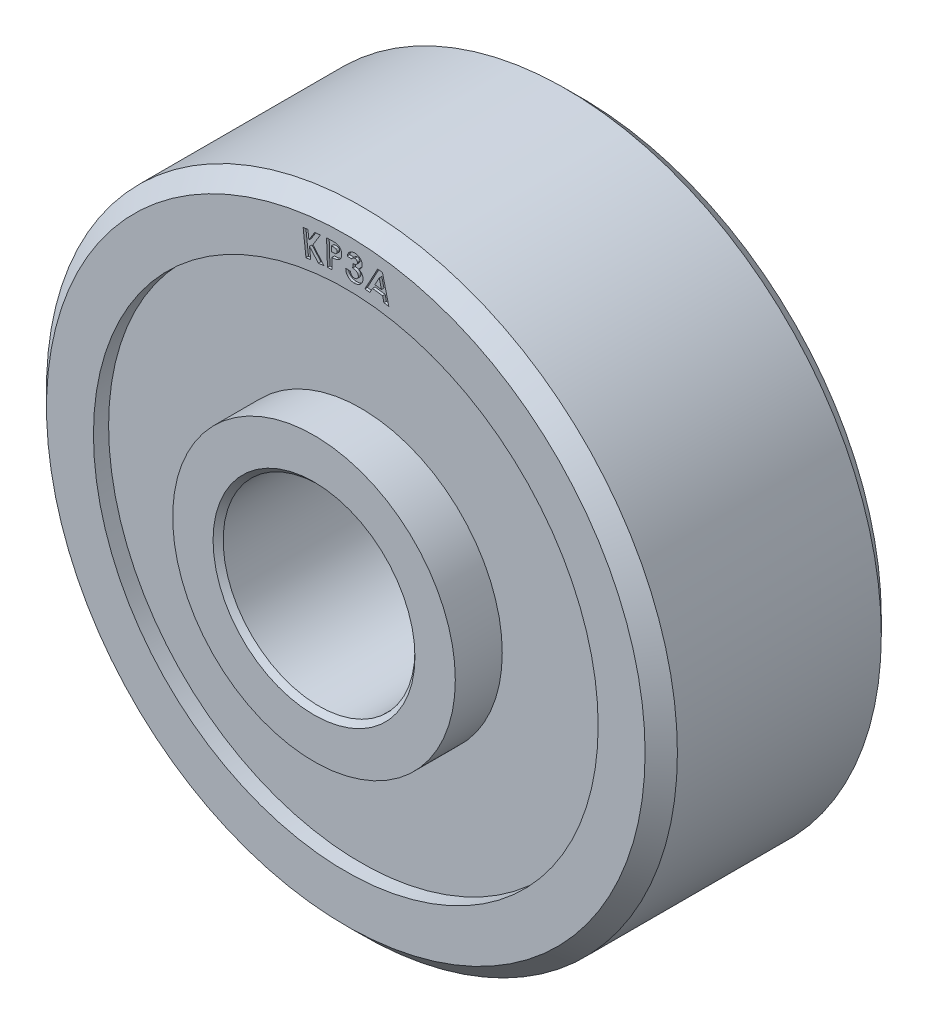
from build123d import *

# Parameters (mm, degrees)
CUT_EXTRUDE1_DEPTH = 0.0635


with BuildPart() as part:
    # Sketch1 → Revolve1 (revolve)
    with BuildSketch(Plane(origin=(0, 0, 0), x_dir=(0, 0, -1), z_dir=(1, 0, 0))):
        Polygon((-3.7719, 2.54), (-3.7719, 3.556), (-2.5908, 3.556), (-2.5908, 6.35), (-2.9718, 6.35), (-2.9718, 7.5311), (-2.5654, 7.9375), (2.5654, 7.9375), (2.9718, 7.5311), (2.9718, 6.35), (2.5908, 6.35), (2.5908, 3.556), (3.7719, 3.556), (3.7719, 2.54), (3.6449, 2.413), (-3.6449, 2.413), align=None)
    revolve(axis=Axis((0, 0, 0), (0, 0, -1)))

    # Sketch2 → Cut-Extrude1 (cut)
    with BuildSketch(Plane.XY.offset(2.9718)):
        Polygon((-1.073681475, 7.149950284), (-0.953219737, 7.163688265), (-0.92879666, 6.9484599), (-0.783530233, 7.182895997), (-0.64017186, 7.199305252), (-0.827033839, 6.895288826), (-0.547694897, 6.576007977), (-0.68889081, 6.559853129), (-0.91365944, 6.815659419), (-0.881985762, 6.537974122), (-1.002447501, 6.524236142), align=None)
        with BuildLine():
            Line((-0.483895388, 7.216524684), (-0.356437455, 7.220976808))
            add(Edge.make_bspline(
                [(-0.356437455, 7.220976808), (-0.348127565, 7.221174763), (-0.332060567, 7.221557506), (-0.30885576, 7.22165103), (-0.287434102, 7.220847317), (-0.267813394, 7.219564911), (-0.249965241, 7.217315038), (-0.233827559, 7.214807961), (-0.219502285, 7.211370346), (-0.20679939, 7.207241827), (-0.195285698, 7.202452443), (-0.184489444, 7.196976494), (-0.174371586, 7.190545045), (-0.164643507, 7.18364255), (-0.155709146, 7.175752396), (-0.147242277, 7.167209654), (-0.139416779, 7.157815249), (-0.13216206, 7.147734921), (-0.125493288, 7.137087541), (-0.119818082, 7.125715329), (-0.114848545, 7.113859232), (-0.110591185, 7.101472639), (-0.107345972, 7.088476793), (-0.104800117, 7.074928752), (-0.102964288, 7.060829844), (-0.102513509, 7.051207939), (-0.102284811, 7.046326367)],
                knots=[0, 0, 0, 0, 2.4937e-05, 4.8215e-05, 6.9599e-05, 8.9238e-05, 0.000107178, 0.000123552, 0.000138207, 0.000151321, 0.000163581, 0.000175585, 0.000187585, 0.000199519, 0.000211329, 0.000223292, 0.000235573, 0.000247964, 0.000260531, 0.000273217, 0.000286045, 0.000299078, 0.000312468, 0.00032619, 0.000340421, 0.000355077, 0.000355077, 0.000355077, 0.000355077], degree=3))
            add(Edge.make_bspline(
                [(-0.102284811, 7.046326367), (-0.10221945, 7.040941319), (-0.102090653, 7.03032981), (-0.10302249, 7.014700607), (-0.105433602, 6.999812313), (-0.108499428, 6.985502152), (-0.113041424, 6.971928231), (-0.118443712, 6.958891094), (-0.125131278, 6.946598266), (-0.132893446, 6.935057889), (-0.141572795, 6.924247517), (-0.151009096, 6.914116137), (-0.16130768, 6.904893953), (-0.172351664, 6.896344793), (-0.184309667, 6.888833082), (-0.196946646, 6.881851982), (-0.210471163, 6.875896783), (-0.219882564, 6.872589605), (-0.224654602, 6.870912705)],
                knots=[0, 0, 0, 0, 1.6155e-05, 3.1834e-05, 4.6892e-05, 6.1365e-05, 7.5686e-05, 8.9766e-05, 0.000103654, 0.00011759, 0.000131436, 0.000145205, 0.000159076, 0.000172865, 0.000187051, 0.000201395, 0.000216145, 0.000231316, 0.000231316, 0.000231316, 0.000231316], degree=3))
            add(Edge.make_bspline(
                [(-0.224654602, 6.870912705), (-0.227823905, 6.86997978), (-0.234696434, 6.867956764), (-0.246063162, 6.865653412), (-0.259162985, 6.863444281), (-0.274089942, 6.861835848), (-0.290728728, 6.859914592), (-0.309235014, 6.858620439), (-0.329503833, 6.857458742), (-0.343631033, 6.856936912), (-0.350967703, 6.85666591)],
                knots=[0, 0, 0, 0, 9.907e-06, 2.1483e-05, 3.4763e-05, 4.9752e-05, 6.651e-05, 8.5008e-05, 0.000105392, 0.000127417, 0.000127417, 0.000127417, 0.000127417], degree=3))
            Line((-0.350967703, 6.85666591), (-0.341554642, 6.589156896))
            Line((-0.341554642, 6.589156896), (-0.461761974, 6.58495918))
            Line((-0.461761974, 6.58495918), (-0.483895388, 7.216524684))
        make_face()
        with BuildLine():
            Line((-0.355038216, 6.973820357), (-0.316877158, 6.975092393))
            add(Edge.make_bspline(
                [(-0.316877158, 6.975092393), (-0.309959449, 6.9753884), (-0.297201618, 6.975934305), (-0.279843375, 6.977875287), (-0.265834277, 6.98007101), (-0.254829165, 6.983249091), (-0.246184433, 6.987579906), (-0.238737157, 6.992537719), (-0.232503589, 6.998742932), (-0.227207837, 7.005840535), (-0.222955991, 7.013830404), (-0.220269028, 7.022737354), (-0.218462128, 7.032260401), (-0.21851933, 7.038854735), (-0.218548833, 7.042255854)],
                knots=[0, 0, 0, 0, 2.0766e-05, 3.8297e-05, 5.2371e-05, 6.3276e-05, 7.2492e-05, 8.1277e-05, 9.0002e-05, 9.8728e-05, 0.000107775, 0.000116987, 0.000126545, 0.000136724, 0.000136724, 0.000136724, 0.000136724], degree=3))
            add(Edge.make_bspline(
                [(-0.218548833, 7.042255854), (-0.21873044, 7.04519037), (-0.219083288, 7.0508919), (-0.220802862, 7.0590735), (-0.223188289, 7.066655055), (-0.226455496, 7.073634686), (-0.230939657, 7.079752879), (-0.235972442, 7.085392653), (-0.241985674, 7.090354688), (-0.246493613, 7.09302784), (-0.248823272, 7.0944093)],
                knots=[0, 0, 0, 0, 8.81e-06, 1.7117e-05, 2.5002e-05, 3.2626e-05, 4.0108e-05, 4.7672e-05, 5.5262e-05, 6.3379e-05, 6.3379e-05, 6.3379e-05, 6.3379e-05], degree=3))
            add(Edge.make_bspline(
                [(-0.248823272, 7.0944093), (-0.250751771, 7.095392779), (-0.254833076, 7.097474129), (-0.261826658, 7.099712609), (-0.269859854, 7.101380369), (-0.278923208, 7.102982514), (-0.289127959, 7.103943951), (-0.300420239, 7.104397059), (-0.312765678, 7.104534188), (-0.321329592, 7.104316916), (-0.325781405, 7.104203971)],
                knots=[0, 0, 0, 0, 6.486e-06, 1.3727e-05, 2.1936e-05, 3.1096e-05, 4.1323e-05, 5.2655e-05, 6.4995e-05, 7.8353e-05, 7.8353e-05, 7.8353e-05, 7.8353e-05], degree=3))
            Line((-0.325781405, 7.104203971), (-0.359617543, 7.10305914))
            Line((-0.359617543, 7.10305914), (-0.355038216, 6.973820357))
        make_face(mode=Mode.SUBTRACT)
        with BuildLine():
            Line((0.150369045, 7.072643459), (0.034868244, 7.077477193))
            add(Edge.make_bspline(
                [(0.034868244, 7.077477193), (0.035930136, 7.083134845), (0.038015251, 7.09424412), (0.042505288, 7.11031614), (0.047995965, 7.125473202), (0.05432215, 7.13980968), (0.061752106, 7.15317407), (0.069986869, 7.165714019), (0.079351921, 7.177277613), (0.086322676, 7.184259549), (0.089820167, 7.18776265)],
                knots=[0, 0, 0, 0, 1.7263e-05, 3.3898e-05, 4.9993e-05, 6.5595e-05, 8.0853e-05, 9.5812e-05, 0.000110553, 0.000125397, 0.000125397, 0.000125397, 0.000125397], degree=3))
            add(Edge.make_bspline(
                [(0.089820167, 7.18776265), (0.094865971, 7.192274987), (0.104860211, 7.201212588), (0.121206297, 7.21270804), (0.138507318, 7.222111377), (0.156533654, 7.229846028), (0.175477636, 7.235592405), (0.195265974, 7.23931578), (0.215872831, 7.241521421), (0.229866253, 7.241216339), (0.236994646, 7.241060927)],
                knots=[0, 0, 0, 0, 2.0296e-05, 4.02e-05, 5.9783e-05, 7.9275e-05, 9.8952e-05, 0.000119034, 0.000139615, 0.000160985, 0.000160985, 0.000160985, 0.000160985], degree=3))
            add(Edge.make_bspline(
                [(0.236994646, 7.241060927), (0.243326567, 7.240680157), (0.255807691, 7.239929605), (0.274004431, 7.236615571), (0.29143556, 7.232077493), (0.30799456, 7.225998017), (0.323653648, 7.218273359), (0.338414905, 7.209087101), (0.352444165, 7.198458605), (0.365305592, 7.186320664), (0.377179935, 7.173386384), (0.387158219, 7.159525384), (0.395899686, 7.145400959), (0.402531779, 7.130538271), (0.407908864, 7.115349451), (0.411286837, 7.099534653), (0.413145645, 7.083247045), (0.412993733, 7.072223968), (0.412917122, 7.066664894)],
                knots=[0, 0, 0, 0, 1.9015e-05, 3.7481e-05, 5.5376e-05, 7.3004e-05, 9.0298e-05, 0.000107665, 0.000125092, 0.000143003, 0.000160655, 0.000177676, 0.000194168, 0.000210391, 0.000226402, 0.00024242, 0.000258799, 0.000275464, 0.000275464, 0.000275464, 0.000275464], degree=3))
            add(Edge.make_bspline(
                [(0.412917122, 7.066664894), (0.41235476, 7.05980872), (0.411240079, 7.046218812), (0.406043562, 7.026458501), (0.39789868, 7.007804099), (0.387022208, 6.990325064), (0.373534633, 6.974196295), (0.357216573, 6.960069836), (0.33865037, 6.947342211), (0.324785783, 6.940798127), (0.317641682, 6.937426111)],
                knots=[0, 0, 0, 0, 2.0607e-05, 4.0847e-05, 6.0957e-05, 8.1466e-05, 0.000102411, 0.00012377, 0.000146033, 0.000169698, 0.000169698, 0.000169698, 0.000169698], degree=3))
            add(Edge.make_bspline(
                [(0.317641682, 6.937426111), (0.32224211, 6.935698678), (0.331301172, 6.932297053), (0.344369065, 6.926332147), (0.35651554, 6.919430047), (0.367977299, 6.911964248), (0.378419285, 6.903438687), (0.388195142, 6.894343798), (0.397222968, 6.884499408), (0.405133722, 6.873803404), (0.412319627, 6.86262639), (0.418401705, 6.850899497), (0.423549689, 6.838747006), (0.427584264, 6.826137821), (0.430707776, 6.813135676), (0.432507079, 6.799669109), (0.433659619, 6.785817667), (0.433400721, 6.776430836), (0.433269686, 6.771679918)],
                knots=[0, 0, 0, 0, 1.474e-05, 2.9026e-05, 4.3037e-05, 5.662e-05, 7.001e-05, 8.3419e-05, 9.6656e-05, 0.000110013, 0.000123281, 0.000136481, 0.000149592, 0.000162827, 0.000176156, 0.000189648, 0.000203551, 0.000217798, 0.000217798, 0.000217798, 0.000217798], degree=3))
            add(Edge.make_bspline(
                [(0.433269686, 6.771679918), (0.432765993, 6.764711087), (0.431776994, 6.751027827), (0.428037351, 6.730975818), (0.422331069, 6.711865528), (0.414582575, 6.693650574), (0.40509285, 6.676242582), (0.393306005, 6.65995426), (0.379980386, 6.644293353), (0.364610651, 6.629962516), (0.347911834, 6.616892312), (0.330107991, 6.605507084), (0.311186133, 6.596161421), (0.291335816, 6.588659086), (0.270460274, 6.583017939), (0.24860161, 6.579425993), (0.225753103, 6.577364888), (0.21020071, 6.577751668), (0.202268084, 6.577948948)],
                knots=[0, 0, 0, 0, 2.0948e-05, 4.1132e-05, 6.1053e-05, 8.0662e-05, 0.000100418, 0.000120395, 0.00014087, 0.000162017, 0.000183315, 0.000204417, 0.000225295, 0.00024651, 0.000267987, 0.000290049, 0.000312898, 0.000336686, 0.000336686, 0.000336686, 0.000336686], degree=3))
            add(Edge.make_bspline(
                [(0.202268084, 6.577948948), (0.194789086, 6.57839721), (0.180137141, 6.579275391), (0.158818194, 6.583036753), (0.138491754, 6.587897585), (0.119470159, 6.595108583), (0.101407507, 6.603495029), (0.08465858, 6.613975504), (0.06894446, 6.625940153), (0.054434463, 6.639564585), (0.041370011, 6.654639685), (0.029947511, 6.671061742), (0.02032282, 6.688665923), (0.012188263, 6.707362205), (0.005999826, 6.72734238), (0.001476395, 6.748460036), (-0.001528162, 6.770750316), (-0.002106289, 6.786001906), (-0.002402389, 6.793813331)],
                knots=[0, 0, 0, 0, 2.2459e-05, 4.3998e-05, 6.4854e-05, 8.5057e-05, 0.000104915, 0.000124506, 0.000144198, 0.000164086, 0.000184106, 0.000203937, 0.000223978, 0.000244205, 0.000265004, 0.000286611, 0.000308937, 0.000332377, 0.000332377, 0.000332377, 0.000332377], degree=3))
            Line((-0.002402389, 6.793813331), (0.116532908, 6.788852394))
            add(Edge.make_bspline(
                [(0.116532908, 6.788852394), (0.117083814, 6.784859736), (0.118155397, 6.777093502), (0.120420684, 6.765904569), (0.123316627, 6.755452946), (0.127086473, 6.745877702), (0.13105794, 6.736830411), (0.135943691, 6.728677636), (0.141423976, 6.72128491), (0.149386698, 6.712448448), (0.160822004, 6.703104322), (0.176726451, 6.695042794), (0.194393457, 6.689662842), (0.206893004, 6.688636262), (0.213334791, 6.688107201)],
                knots=[0, 0, 0, 0, 1.2089e-05, 2.3515e-05, 3.4226e-05, 4.4573e-05, 5.4363e-05, 6.3831e-05, 7.3016e-05, 8.1932e-05, 9.9474e-05, 0.00011694, 0.00013513, 0.000154474, 0.000154474, 0.000154474, 0.000154474], degree=3))
            add(Edge.make_bspline(
                [(0.213334791, 6.688107201), (0.216771217, 6.688039897), (0.223530094, 6.687907521), (0.233443515, 6.688862166), (0.242989812, 6.690490656), (0.25212156, 6.693016148), (0.260831182, 6.696454074), (0.269065034, 6.700872918), (0.276904644, 6.706059487), (0.284325582, 6.712017711), (0.29091538, 6.718751106), (0.297039218, 6.725727582), (0.302114685, 6.7333353), (0.306465929, 6.741262829), (0.309780733, 6.749704966), (0.312345821, 6.758466048), (0.313995689, 6.767683154), (0.314473578, 6.773963686), (0.314716001, 6.777149669)],
                knots=[0, 0, 0, 0, 1.0303e-05, 2.0265e-05, 2.9822e-05, 3.9328e-05, 4.8635e-05, 5.7853e-05, 6.7308e-05, 7.6804e-05, 8.6339e-05, 9.5541e-05, 0.000104609, 0.000113715, 0.00012262, 0.000131758, 0.000141065, 0.000150647, 0.000150647, 0.000150647, 0.000150647], degree=3))
            add(Edge.make_bspline(
                [(0.314716001, 6.777149669), (0.314772436, 6.780674639), (0.314883774, 6.787628888), (0.313336058, 6.797852822), (0.31100345, 6.807753906), (0.307261441, 6.817251629), (0.302193719, 6.826318554), (0.296133621, 6.835121836), (0.288725633, 6.843412845), (0.280399706, 6.851443046), (0.270866439, 6.858809615), (0.260180433, 6.865320079), (0.24844349, 6.871068228), (0.235561648, 6.875853751), (0.221650373, 6.879800046), (0.206670275, 6.882791386), (0.190666155, 6.88513534), (0.179591005, 6.885898341), (0.173901698, 6.886290294)],
                knots=[0, 0, 0, 0, 1.0559e-05, 2.0831e-05, 3.0919e-05, 4.1029e-05, 5.1333e-05, 6.2025e-05, 7.3022e-05, 8.4629e-05, 9.6689e-05, 0.000109081, 0.000122108, 0.000135835, 0.00015025, 0.000165443, 0.000181633, 0.000198736, 0.000198736, 0.000198736, 0.000198736], degree=3))
            Line((0.173901698, 6.886290294), (0.178226618, 6.98932515))
            add(Edge.make_bspline(
                [(0.178226618, 6.98932515), (0.18501609, 6.989670849), (0.197736294, 6.990318523), (0.215445674, 6.992377331), (0.23044638, 6.995495533), (0.243045413, 6.999551518), (0.253627385, 7.004825929), (0.262895067, 7.010896009), (0.270840844, 7.018165487), (0.277696369, 7.026136065), (0.283387056, 7.034771486), (0.287367675, 7.043969102), (0.290273968, 7.053438633), (0.290793654, 7.059944383), (0.291056145, 7.063230398)],
                knots=[0, 0, 0, 0, 2.0392e-05, 3.8205e-05, 5.3424e-05, 6.6296e-05, 7.7788e-05, 8.8795e-05, 9.9422e-05, 0.000109977, 0.00012028, 0.000130302, 0.000139965, 0.000149826, 0.000149826, 0.000149826, 0.000149826], degree=3))
            add(Edge.make_bspline(
                [(0.291056145, 7.063230398), (0.291021451, 7.067362649), (0.290953924, 7.075405712), (0.287861118, 7.087022817), (0.28261, 7.097644381), (0.2749538, 7.106948958), (0.265596835, 7.114842943), (0.25453853, 7.120824966), (0.241925264, 7.124554319), (0.232992, 7.125299616), (0.228344807, 7.125687329)],
                knots=[0, 0, 0, 0, 1.2355e-05, 2.4048e-05, 3.571e-05, 4.765e-05, 5.993e-05, 7.2224e-05, 8.5102e-05, 9.9066e-05, 9.9066e-05, 9.9066e-05, 9.9066e-05], degree=3))
            add(Edge.make_bspline(
                [(0.228344807, 7.125687329), (0.224136814, 7.125651082), (0.215772585, 7.125579032), (0.203449652, 7.123108126), (0.191657066, 7.118533997), (0.18062123, 7.112090416), (0.170603124, 7.104147604), (0.162052758, 7.094869682), (0.155196237, 7.084307897), (0.151989871, 7.076560025), (0.150369045, 7.072643459)],
                knots=[0, 0, 0, 0, 1.2603e-05, 2.5052e-05, 3.7454e-05, 5.0392e-05, 6.3245e-05, 7.5669e-05, 8.8089e-05, 0.000100785, 0.000100785, 0.000100785, 0.000100785], degree=3))
        make_face()
        Polygon((0.802065182, 7.179671183), (0.922781328, 7.164025149), (1.082294549, 6.507018939), (0.958525518, 6.523173787), (0.926343026, 6.658391135), (0.671172754, 6.691464051), (0.603373275, 6.569221463), (0.479604244, 6.585376311), align=None)
        Polygon((0.841752682, 7.005911167), (0.730449597, 6.801876712), (0.896704605, 6.780252112), align=None, mode=Mode.SUBTRACT)
    extrude(amount=-CUT_EXTRUDE1_DEPTH, mode=Mode.SUBTRACT)


solid = part.part
